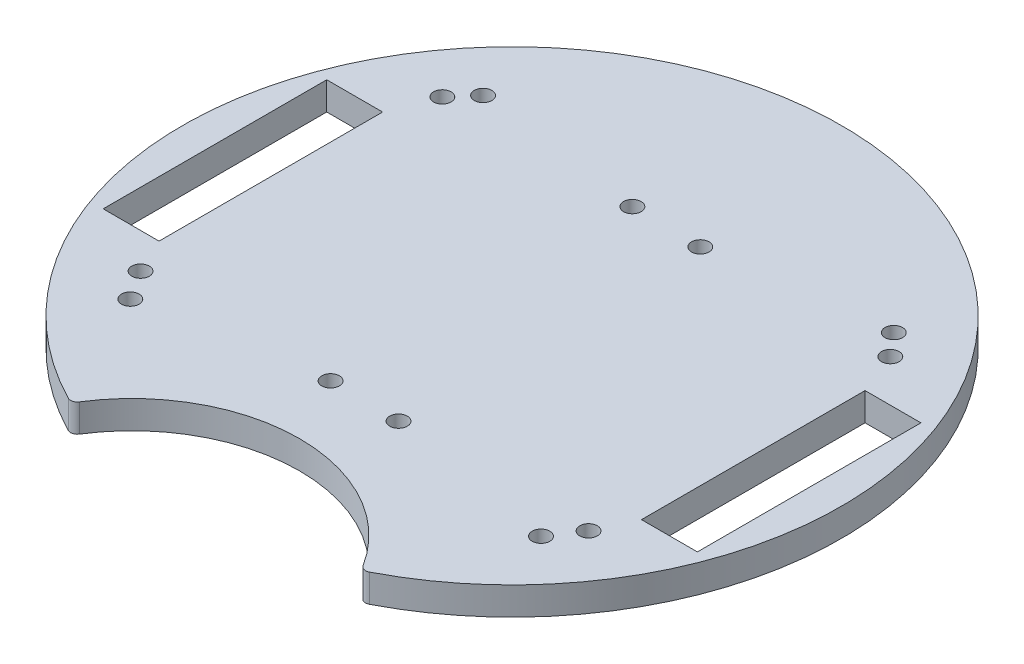
from build123d import *

# Parameters (mm, degrees)
SKETCH1_R           = 2
SKETCH1_W           = 12.7
SKETCH1_H           = 50.8
BOSS_EXTRUDE3_DEPTH = 6.35


with BuildPart() as part:
    # Sketch1 → Boss-Extrude3 (new body)
    with BuildSketch(Plane(origin=(0, 0, 0), x_dir=(1, 0, 0), z_dir=(0, 1, 0))):
        with BuildLine():
            ThreePointArc((32.240681933, -66.10056535), (0, -48.302004425), (-32.240681933, -66.10056535))
            ThreePointArc((-32.240681933, -66.10056535), (-33.11372382, -66.748004461), (-34.194833578, -66.63583839))
            ThreePointArc((-34.194833578, -66.63583839), (0, 74.897407173), (34.194833578, -66.63583839))
            ThreePointArc((34.194833578, -66.63583839), (33.11372382, -66.748004461), (32.240681933, -66.10056535))
        make_face()
        with Locations((-51.004123727, -33.414457974)):
            Circle(SKETCH1_R, mode=Mode.SUBTRACT)
        with Locations((7.824123727, -33.623956053)):
            Circle(SKETCH1_R, mode=Mode.SUBTRACT)
        with Locations((51.004123727, -33.623956053)):
            Circle(SKETCH1_R, mode=Mode.SUBTRACT)
        with Locations((51.004123727, 34.956043947)):
            Circle(SKETCH1_R, mode=Mode.SUBTRACT)
        with Locations((-7.824123727, 35.165542026)):
            Circle(SKETCH1_R, mode=Mode.SUBTRACT)
        with Locations((-7.824123727, -33.414457974)):
            Circle(SKETCH1_R, mode=Mode.SUBTRACT)
        with Locations((-51.004123727, 35.165542026)):
            Circle(SKETCH1_R, mode=Mode.SUBTRACT)
        with Locations((-46.663733983, -40.081231883)):
            Circle(SKETCH1_R, mode=Mode.SUBTRACT)
        with Locations((46.663733983, -40.081231883)):
            Circle(SKETCH1_R, mode=Mode.SUBTRACT)
        with Locations((46.663733983, 40.081231883)):
            Circle(SKETCH1_R, mode=Mode.SUBTRACT)
        with Locations((-46.663733983, 40.081231883)):
            Circle(SKETCH1_R, mode=Mode.SUBTRACT)
        with Locations((7.824123727, 34.956043947)):
            Circle(SKETCH1_R, mode=Mode.SUBTRACT)
        with Locations((61.164123727, 0)):
            Rectangle(SKETCH1_W, SKETCH1_H, mode=Mode.SUBTRACT)
        with Locations((-61.164123727, 0)):
            Rectangle(SKETCH1_W, SKETCH1_H, mode=Mode.SUBTRACT)
    extrude(amount=BOSS_EXTRUDE3_DEPTH)


solid = part.part
